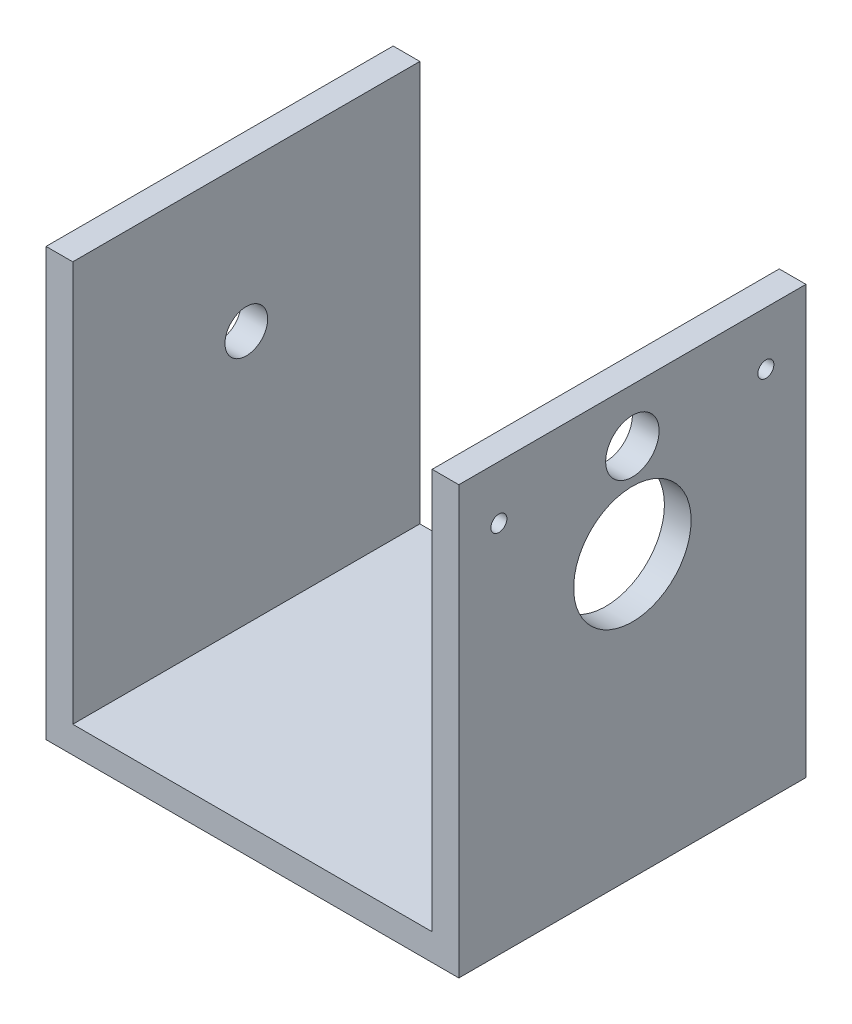
from build123d import *

# Parameters (mm, degrees)
SKETCH1_R           = 11
SKETCH1_R_2         = 5
SKETCH1_R_3         = 1.5
BOSS_EXTRUDE1_DEPTH = 5
SKETCH2_W           = 5
SKETCH2_H           = 65
BOSS_EXTRUDE2_DEPTH = 25
SKETCH3_W           = 72.3
SKETCH3_H           = 65
BOSS_EXTRUDE3_DEPTH = 5
SKETCH4_W           = 65
SKETCH4_H           = 75
SKETCH4_R           = 4
BOSS_EXTRUDE4_DEPTH = 5


with BuildPart() as part:
    # Sketch1 → Boss-Extrude1 (new body)
    with BuildSketch(Plane(origin=(0, 0, 0), x_dir=(0, 0, -1), z_dir=(1, 0, 0))):
        Polygon((-17.5, 27.5), (-27.5, 27.5), (-27.5, 17.5), (-27.5, -27.5), (37.5, -27.5), (37.5, 7.5), (37.5, 27.5), (17.5, 27.5), align=None)
        with Locations((5, 0)):
            Circle(SKETCH1_R, mode=Mode.SUBTRACT)
        with Locations((5, 17.5)):
            Circle(SKETCH1_R_2, mode=Mode.SUBTRACT)
        with Locations((30, 17.5)):
            Circle(SKETCH1_R_3, mode=Mode.SUBTRACT)
        with Locations((-20, 17.5)):
            Circle(SKETCH1_R_3, mode=Mode.SUBTRACT)
    extrude(amount=BOSS_EXTRUDE1_DEPTH)

    # Sketch2 → Boss-Extrude2 (add)
    with BuildSketch(Plane.XZ.offset(27.5)):
        with Locations((2.5, -5)):
            Rectangle(SKETCH2_W, SKETCH2_H)
    extrude(amount=BOSS_EXTRUDE2_DEPTH)

    # Sketch3 → Boss-Extrude3 (add)
    with BuildSketch(Plane.XZ.offset(52.5)):
        with Locations((-36.15, -5)):
            Rectangle(SKETCH3_W, SKETCH3_H)
    extrude(amount=-BOSS_EXTRUDE3_DEPTH)

    # Sketch4 → Boss-Extrude4 (add)
    with BuildSketch(Plane.ZY.offset(72.3)):
        with Locations((-5, -10)):
            Rectangle(SKETCH4_W, SKETCH4_H)
        with Locations((-5, 0)):
            Circle(SKETCH4_R, mode=Mode.SUBTRACT)
    extrude(amount=-BOSS_EXTRUDE4_DEPTH)


solid = part.part
